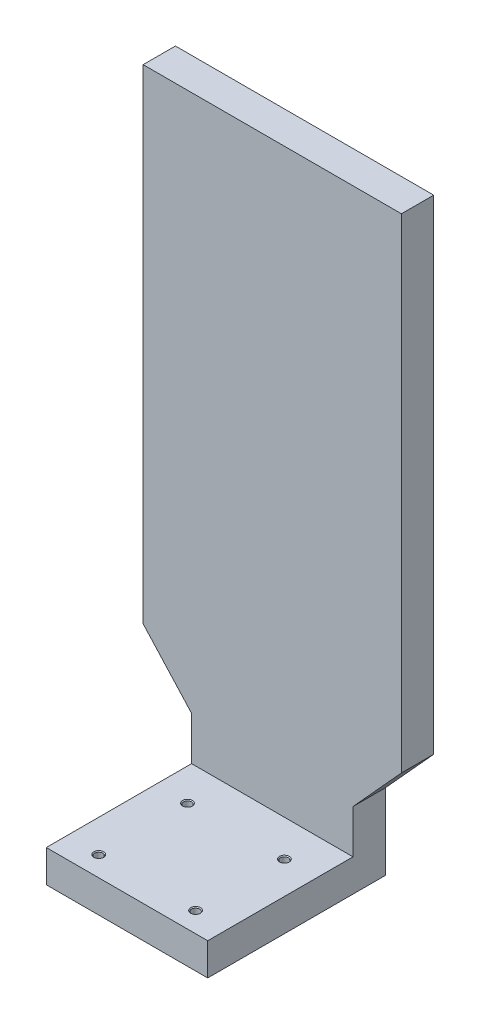
from build123d import *

# Parameters (mm, degrees)
SKIZZE1_W                            = 160
SKIZZE1_H                            = 300
SKIZZE1_W_2                          = 100
SKIZZE1_H_2                          = 27
AUFSATZ_LINEAR_AUSTRAGEN1_DEPTH      = 20
SKIZZE2_W                            = 100
SKIZZE2_H                            = 20
AUFSATZ_LINEAR_AUSTRAGEN2_DEPTH      = 90
AUFSATZ_LINEAR_AUSTRAGEN2_DEPTH_BACK = 20
M6_GEWINDEBOHRUNG1_D                 = 5
M6_GEWINDEBOHRUNG1_CSINK_D           = 6.05
M6_GEWINDEBOHRUNG1_CSINK_ANGLE       = 90


with BuildPart() as part:
    # Skizze1 → Aufsatz-Linear austragen1 (new body)
    with BuildSketch(Plane.XY):
        with Locations((80, 150)):
            Rectangle(SKIZZE1_W, SKIZZE1_H)
        Polygon((0, 0), (160, 0), (130, -33), (30, -33), align=None)
        with Locations((80, -46.5)):
            Rectangle(SKIZZE1_W_2, SKIZZE1_H_2)
    extrude(amount=AUFSATZ_LINEAR_AUSTRAGEN1_DEPTH)

    # Skizze2 → Aufsatz-Linear austragen2 (add, two sides)
    with BuildSketch(Plane.XY.offset(20)) as aufsatz_linear_austragen2_sk:
        with Locations((80, -70)):
            Rectangle(SKIZZE2_W, SKIZZE2_H)
    extrude(amount=AUFSATZ_LINEAR_AUSTRAGEN2_DEPTH)
    extrude(aufsatz_linear_austragen2_sk.sketch, amount=-AUFSATZ_LINEAR_AUSTRAGEN2_DEPTH_BACK)

    # M6 Gewindebohrung1 (through all)
    with Locations(Plane(origin=(0, -60, 0), x_dir=(1, 0, 0), z_dir=(0, 1, 0))):
        with Locations((50, -97.5), (110, -97.5), (110, -42.5), (50, -42.5)):
            CounterSinkHole(M6_GEWINDEBOHRUNG1_D / 2, M6_GEWINDEBOHRUNG1_CSINK_D / 2, counter_sink_angle=M6_GEWINDEBOHRUNG1_CSINK_ANGLE)


solid = part.part
